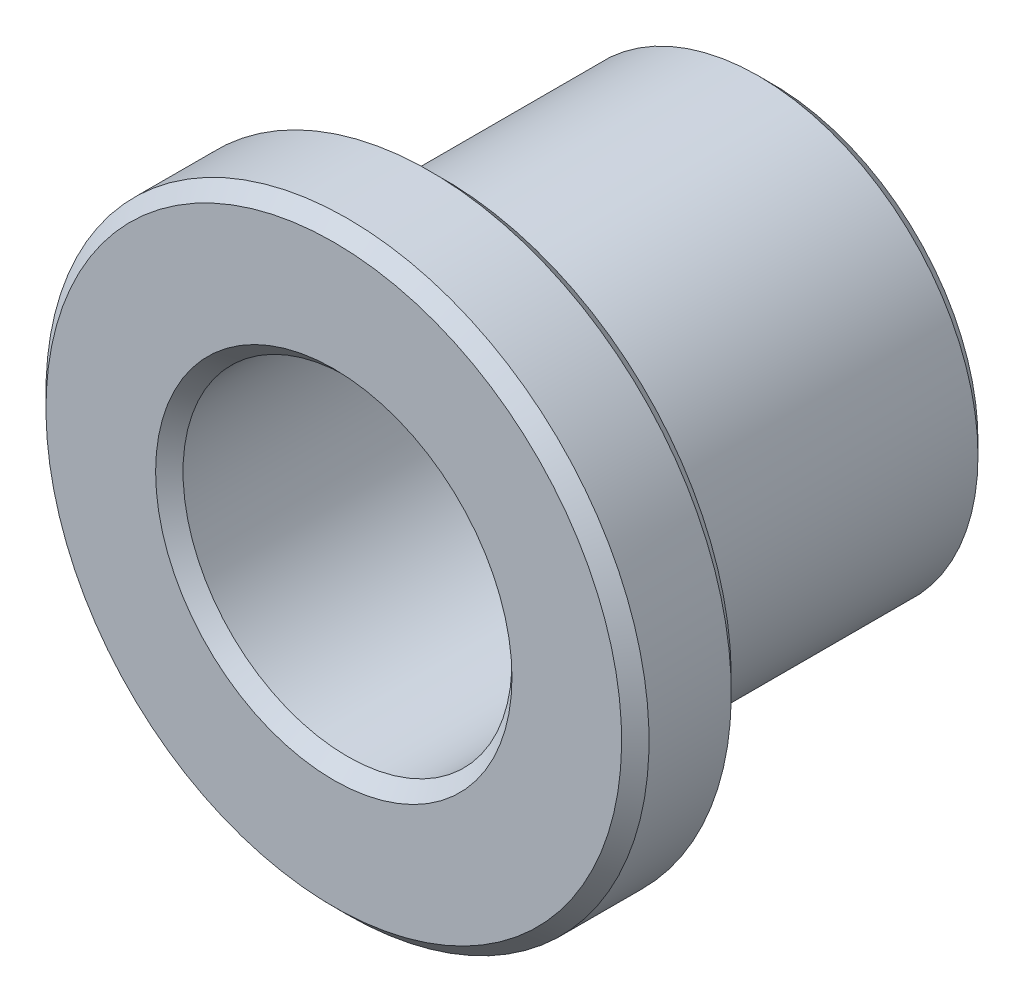
from build123d import *

# Parameters (mm, degrees)
CHAMFER1_SIZE = 0.25


with BuildPart() as part:
    # Sketch1 → Revolve1 (revolve)
    with BuildSketch(Plane(origin=(0, 0, 0), x_dir=(0, 0, -1), z_dir=(1, 0, 0)), mode=Mode.PRIVATE) as revolve1_sk:
        Polygon((0, 3), (0, 5.5), (2, 5.5), (2, 4), (8, 4), (8, 3), align=None)
    revolve(revolve1_sk.sketch.rotate(Axis((0, 0, 0), (0, 0, -1)), 180), axis=Axis((0, 0, 0), (0, 0, -1)))  # turned: the seam where the file's is

    # Chamfer1
    chamfer1_edges = [part.edges().sort_by_distance(p)[0] for p in [
        (0, 3, -8),
        (0, 4, -8),
        (0, 5.5, -2),
        (0, 5.5, 0),
        (0, 3, 0),
    ]]
    chamfer(chamfer1_edges, length=CHAMFER1_SIZE)


solid = part.part
